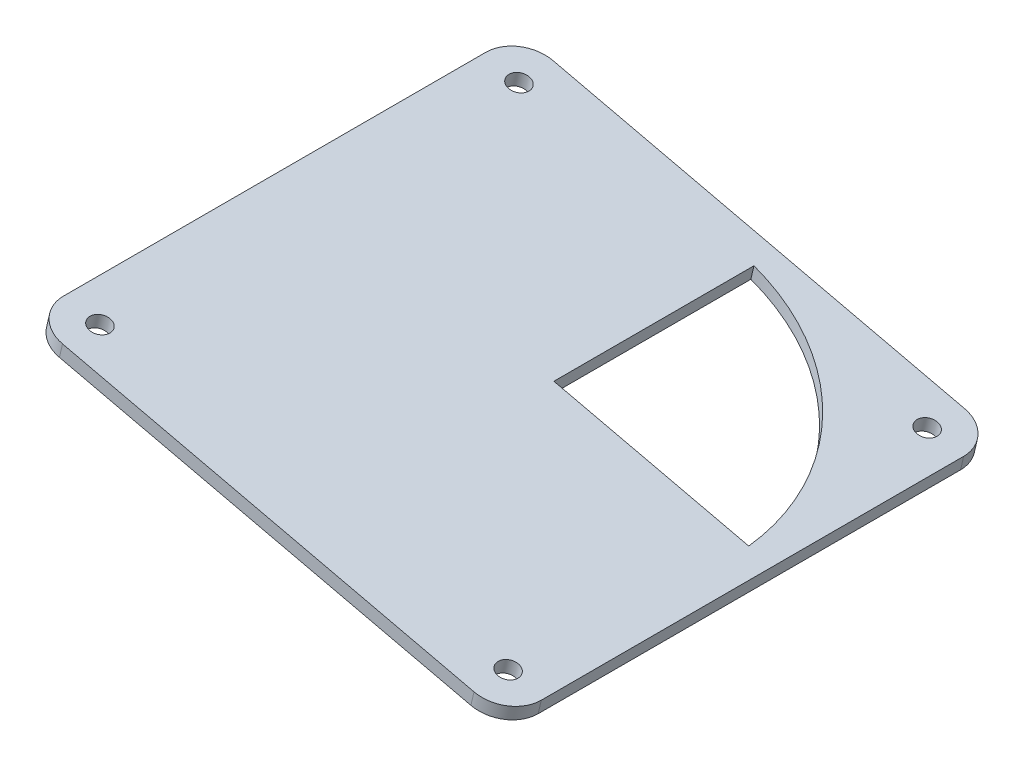
from build123d import *

# Parameters (mm, degrees)
SKETCH1_R           = 1.5
SKETCH1_R_2         = 32.5
BOSS_EXTRUDE1_DEPTH = 2
BOSS_EXTRUDE2_DEPTH = 2


with BuildPart() as part:
    # Sketch1 → Boss-Extrude1 (new body)
    with BuildSketch(Plane(origin=(12.910322113, 55.576390481, 0), x_dir=(0.974063756, -0.226273724, 0), z_dir=(0.226273724, 0.974063756, 0))):
        with BuildLine():
            Line((-65.421780539, -70.276441512), (-3.421780539, -70.276441512))
            ThreePointArc((-3.421780539, -70.276441512), (0.113753366, -68.811975418), (1.578219461, -65.276441512))
            Line((1.578219461, -65.276441512), (1.578219461, -3.276441512))
            ThreePointArc((1.578219461, -3.276441512), (0.113753366, 0.259092394), (-3.421780539, 1.723558488))
            Line((-3.421780539, 1.723558488), (-65.421780539, 1.723558488))
            ThreePointArc((-65.421780539, 1.723558488), (-68.957314445, 0.259092394), (-70.421780539, -3.276441512))
            Line((-70.421780539, -3.276441512), (-70.421780539, -65.276441512))
            ThreePointArc((-70.421780539, -65.276441512), (-68.957314445, -68.811975418), (-65.421780539, -70.276441512))
        make_face()
        with Locations((-65.171780539, -3.526441512)):
            Circle(SKETCH1_R, mode=Mode.SUBTRACT)
        with Locations((-65.171780539, -65.026441512)):
            Circle(SKETCH1_R, mode=Mode.SUBTRACT)
        with Locations((-3.671780539, -65.026441512)):
            Circle(SKETCH1_R, mode=Mode.SUBTRACT)
        with Locations((-3.671780539, -3.526441512)):
            Circle(SKETCH1_R, mode=Mode.SUBTRACT)
        with Locations((-34.421780539, -34.276441512)):
            Circle(SKETCH1_R_2, mode=Mode.SUBTRACT)
    extrude(amount=BOSS_EXTRUDE1_DEPTH)

    # Sketch2 → Boss-Extrude2 (add)
    with BuildSketch(Plane(origin=(13.362869562, 57.524517994, 0), x_dir=(0.974063756, -0.226273724, 0), z_dir=(0.226273724, 0.974063756, 0))):
        with BuildLine():
            Line((-2.060538289, -31.276441512), (-31.421780539, -31.276441512))
            Line((-31.421780539, -31.276441512), (-31.421780539, -1.915199262))
            ThreePointArc((-31.421780539, -1.915199262), (-57.402750928, -57.257411901), (-2.060538289, -31.276441512))
        make_face()
    extrude(amount=-BOSS_EXTRUDE2_DEPTH)


solid = part.part
